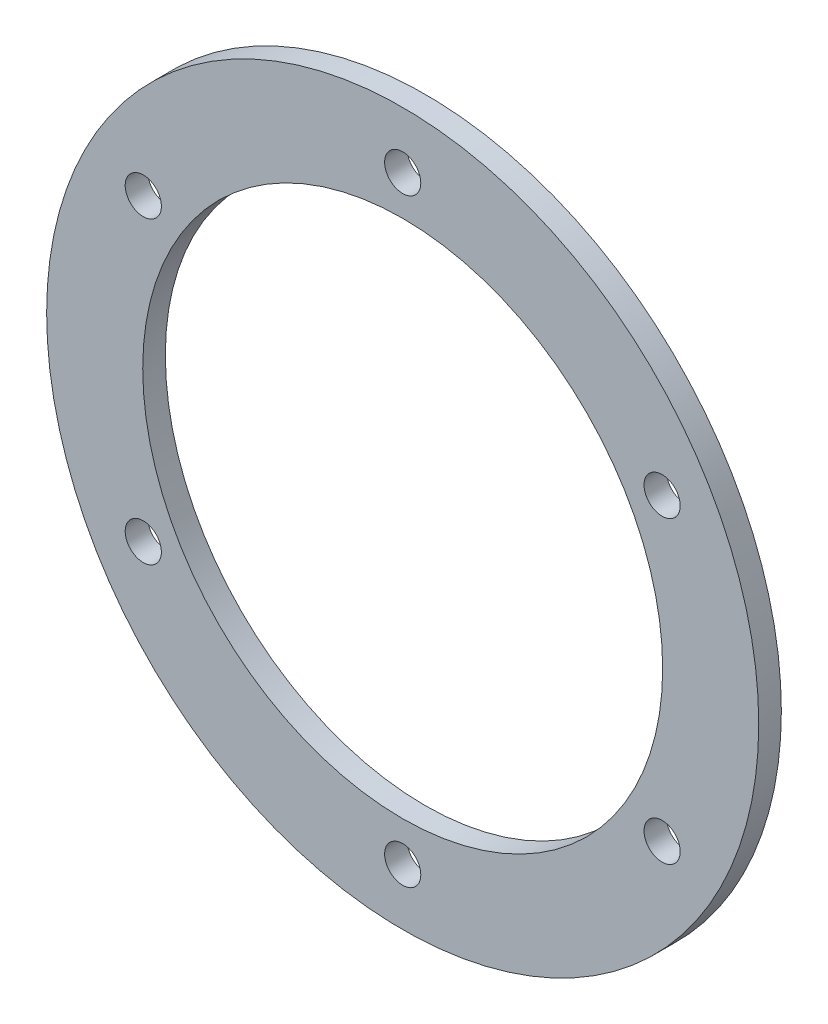
from build123d import *

# Parameters (mm, degrees)
SKETCH_1_R      = 31.5
SKETCH_1_R_2    = 23
SKETCH_1_R_3    = 1.6
EXTRUDE_1_DEPTH = 2


with BuildPart() as part:
    # 草图1 → 凸台-拉伸1 (new body)
    with BuildSketch(Plane.XY):
        Circle(SKETCH_1_R)
        Circle(SKETCH_1_R_2, mode=Mode.SUBTRACT)
        with Locations((0, 26.5)):
            Circle(SKETCH_1_R_3, mode=Mode.SUBTRACT)
        with Locations((22.9496732, 13.25)):
            Circle(SKETCH_1_R_3, mode=Mode.SUBTRACT)
        with Locations((22.9496732, -13.25)):
            Circle(SKETCH_1_R_3, mode=Mode.SUBTRACT)
        with Locations((0, -26.5)):
            Circle(SKETCH_1_R_3, mode=Mode.SUBTRACT)
        with Locations((-22.9496732, -13.25)):
            Circle(SKETCH_1_R_3, mode=Mode.SUBTRACT)
        with Locations((-22.9496732, 13.25)):
            Circle(SKETCH_1_R_3, mode=Mode.SUBTRACT)
    extrude(amount=EXTRUDE_1_DEPTH)


solid = part.part
